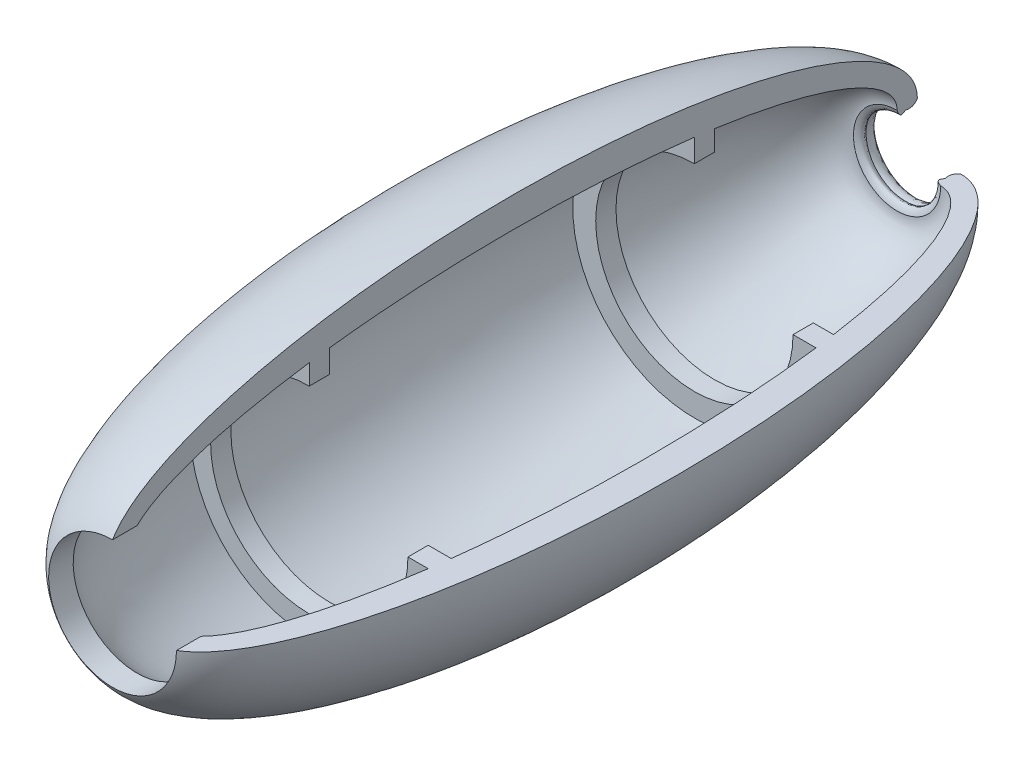
from build123d import *

# Parameters (mm, degrees)
REVOLVE3_ANGLE = 270


with BuildPart() as part:
    # Sketch1 → Revolve3 (revolve)
    with BuildSketch(Plane(origin=(0, 0, 0), x_dir=(0, 0, -1), z_dir=(1, 0, 0))):
        with BuildLine():
            add(Edge.make_bspline(
                [(115.7465953, -1.008655183), (114.892603244, -1.634204905), (114.264623631, -1.959063002), (113.639238781, 0)],
                knots=[0.465469081, 0.465469081, 0.465469081, 0.465469081, 1, 1, 1, 1], degree=3))
            add(Edge.make_bspline(
                [(113.639238781, 0), (113.639238781, 12.165321536), (68.639238781, 18.568122345)],
                knots=[3.141592654, 3.141592654, 3.141592654, 4.158127146, 4.158127146, 4.158127146], degree=2, weights=[1, 0.873589088, 1]))
            Line((68.639238781, 18.568122345), (68.639238781, 13.568122345))
            Line((68.639238781, 13.568122345), (63.639238781, 13.568122345))
            Line((63.639238781, 13.568122345), (63.639238781, 19.232101882))
            add(Edge.make_bspline(
                [(63.639238781, 19.232101882), (18.639238781, 24.801791276), (-26.360761219, 19.232101882)],
                knots=[1.077097687, 1.077097687, 1.077097687, 2.064494967, 2.064494967, 2.064494967], degree=2, weights=[1, 0.880586152, 1]))
            Line((-26.360761219, 19.232101882), (-26.360761219, 13.568122345))
            Line((-26.360761219, 13.568122345), (-31.360761219, 13.568122345))
            Line((-31.360761219, 13.568122345), (-31.360761219, 18.568122345))
            add(Edge.make_bspline(
                [(-31.360761219, 18.568122345), (-64.825670935, 13.806585656), (-73.837058596, 5)],
                knots=[2.125058161, 2.125058161, 2.125058161, 2.910578584, 2.910578584, 2.910578584], degree=2, weights=[1, 0.923856138, 1]))
            Line((-73.837058596, 5), (-79.893391232, 5))
            add(Edge.make_bspline(
                [(118.639238781, 0), (118.639238781, 26.883956752), (27.204780174, 29.186713196), (-64.229678433, 31.489469639), (-79.893391232, 5)],
                knots=[0, 0, 0, 1.485035825, 1.485035825, 2.970071651, 2.970071651, 2.970071651], degree=2, weights=[1, 0.736768422, 1, 0.736768422, 1]))
            add(Edge.make_bspline(
                [(118.639238781, 0), (117.988045153, -1.021098807), (117.023830916, -1.357317272), (115.7465953, -1.008655183)],
                knots=[0, 0, 0, 0, 0.670728869, 0.670728869, 0.670728869, 0.670728869], degree=3))
        make_face()
    revolve(axis=Axis((0, -10.77, -129.717244309), (0, 0, 1)), revolution_arc=REVOLVE3_ANGLE)


solid = part.part
